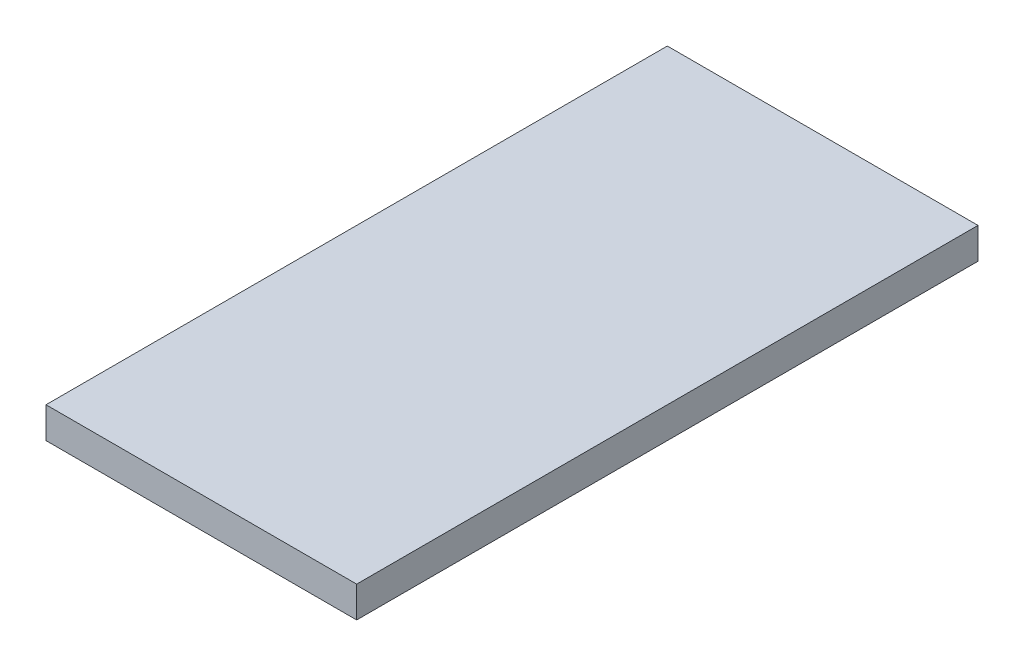
from build123d import *

# Parameters (mm, degrees)
SKETCH1_W                 = 63.5
SKETCH1_H                 = 127
BOSS_EXTRUDE1_DEPTH       = 3.175
F_2_56_TAPPED_HOLE1_D     = 1.778
F_2_56_TAPPED_HOLE1_DEPTH = 5.588
F_2_56_TAPPED_HOLE1_TIP   = 0.53416509


with BuildPart() as part:
    # Sketch1 → Boss-Extrude1 (new body, symmetric)
    with BuildSketch(Plane(origin=(0, 0, 0), x_dir=(1, 0, 0), z_dir=(0, 1, 0))):
        Rectangle(SKETCH1_W, SKETCH1_H)
    extrude(amount=BOSS_EXTRUDE1_DEPTH, both=True)

    # #2-56 Tapped Hole1
    with Locations(Plane.ZY.offset(31.75)):
        with Locations((-22.225, 0)):
            Hole(F_2_56_TAPPED_HOLE1_D / 2, depth=F_2_56_TAPPED_HOLE1_DEPTH)
            with Locations((0, 0, -(F_2_56_TAPPED_HOLE1_DEPTH + F_2_56_TAPPED_HOLE1_TIP / 2))):  # 118° drill point
                Cone(0, F_2_56_TAPPED_HOLE1_D / 2, F_2_56_TAPPED_HOLE1_TIP, mode=Mode.SUBTRACT)


solid = part.part
